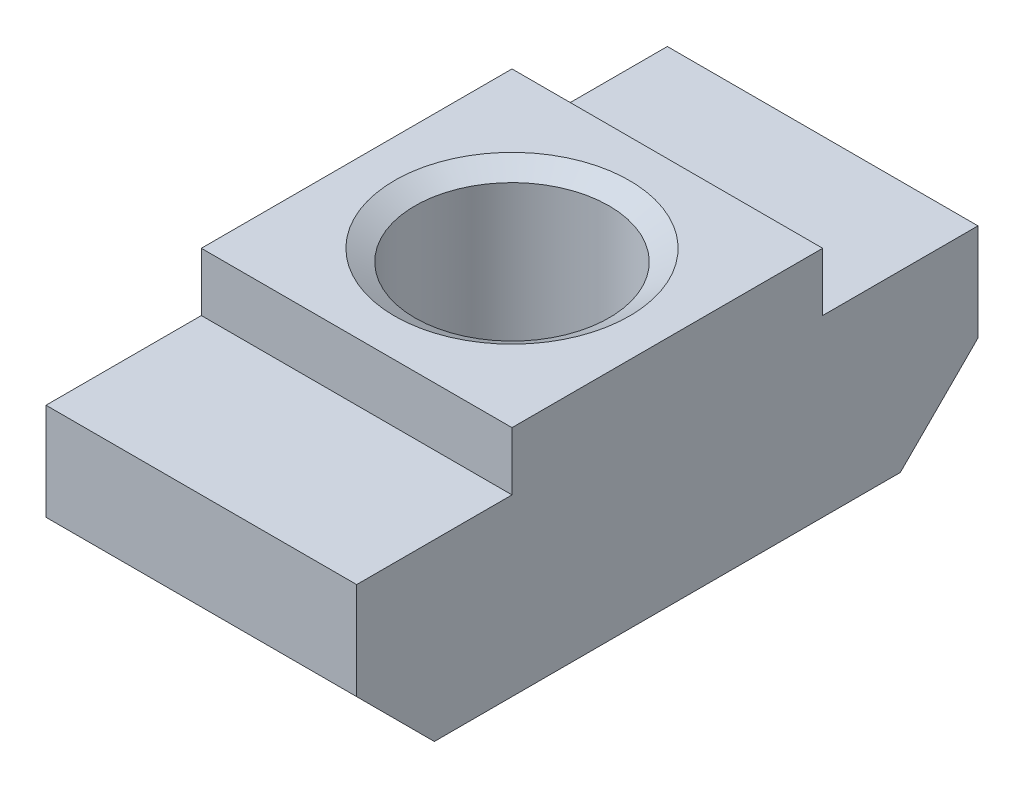
from build123d import *

# Parameters (mm, degrees)
SCHIZZO1_W                      = 8
SCHIZZO1_H                      = 6
ESTRUSIONE_ESTRUSIONE1_DEPTH    = 16
FORO_FILETTATO_M6_1_D           = 5
FORO_FILETTATO_M6_1_CSINK_D     = 6.05
FORO_FILETTATO_M6_1_CSINK_ANGLE = 120
SCHIZZO4_W                      = 4
SCHIZZO4_H                      = 1.5
TAGLIO_ESTRUSIONE1_DEPTH        = 10


with BuildPart() as part:
    # Schizzo1 → Estrusione-Estrusione1 (new body)
    with BuildSketch(Plane.XY):
        with Locations((0, 3)):
            Rectangle(SCHIZZO1_W, SCHIZZO1_H)
    extrude(amount=ESTRUSIONE_ESTRUSIONE1_DEPTH)

    # Foro filettato M6-1 (through all)
    with Locations(Plane(origin=(0, 6, 0), x_dir=(1, 0, 0), z_dir=(0, 1, 0))):
        with Locations((0, -8)):
            CounterSinkHole(FORO_FILETTATO_M6_1_D / 2, FORO_FILETTATO_M6_1_CSINK_D / 2, counter_sink_angle=FORO_FILETTATO_M6_1_CSINK_ANGLE)

    # Schizzo4 → Taglio-Estrusione1 (cut)
    with BuildSketch(Plane.ZY.offset(4)):
        Polygon((0, 0), (0, 2), (2, 0), align=None)
        Polygon((16, 0), (16, 2), (14, 0), align=None)
        with Locations((14, 5.25)):
            Rectangle(SCHIZZO4_W, SCHIZZO4_H)
        with Locations((2, 5.25)):
            Rectangle(SCHIZZO4_W, SCHIZZO4_H)
    extrude(amount=-TAGLIO_ESTRUSIONE1_DEPTH, mode=Mode.SUBTRACT)


solid = part.part
